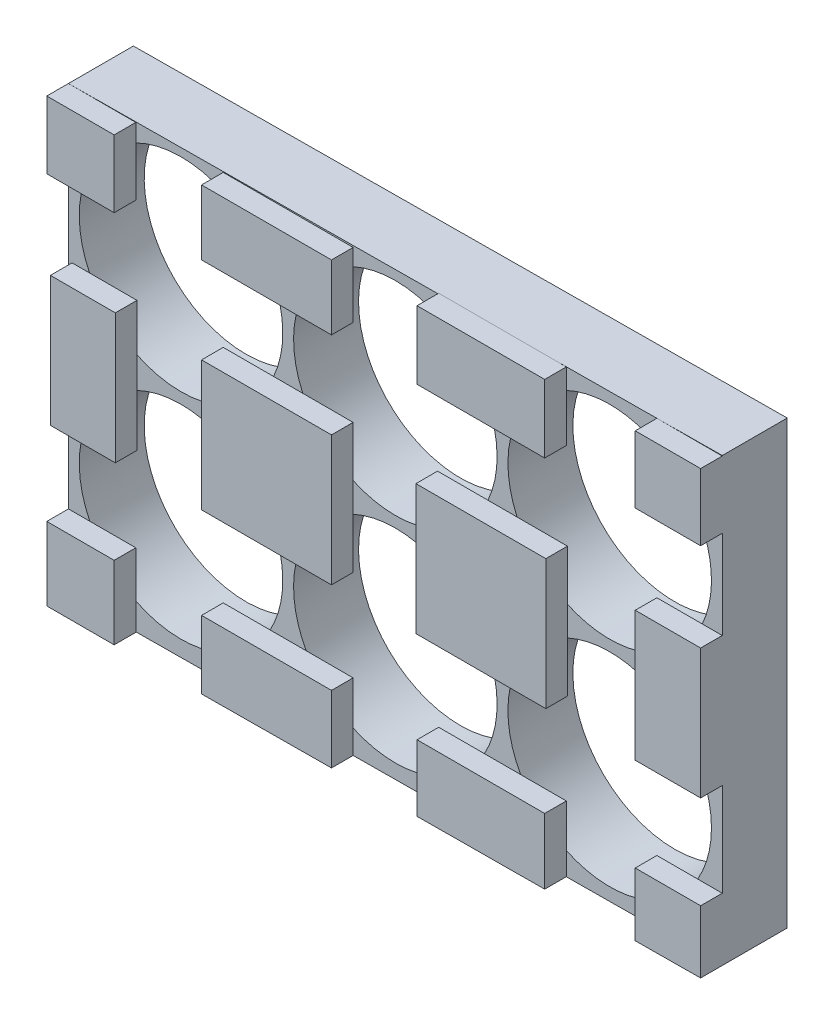
from build123d import *

# Parameters (mm, degrees)
MODEL_R         = 9.4
MODEL_R_2       = 2.5
EXTRUDE_1_DEPTH = 6
SKETCH_2_W      = 6.222861065
SKETCH_2_H      = 6.222861065
SKETCH_2_W_2    = 12
SKETCH_2_H_2    = 6
SKETCH_2_W_3    = 11.79
SKETCH_2_H_3    = 6.29
SKETCH_2_W_4    = 6.039723033
SKETCH_2_H_4    = 6.178960273
SKETCH_2_H_5    = 12
SKETCH_2_W_5    = 6
SKETCH_2_H_6    = 6.764977387
EXTRUDE_2_DEPTH = 2


with BuildPart() as part:
    # Model → 凸台-拉伸1 (new body)
    with BuildSketch(Plane.XY):
        Polygon((1072.862228674, 1168.347447046), (1072.862228674, 1127.547447046), (1012.463824187, 1127.108430595), (1012.463824187, 1167.908430595), align=None)
        with Locations((1022.862228674, 1157.847447046)):
            Circle(MODEL_R, mode=Mode.SUBTRACT)
        with Locations((1042.662228674, 1157.847447046)):
            Circle(MODEL_R, mode=Mode.SUBTRACT)
        with Locations((1062.462228674, 1157.847447046)):
            Circle(MODEL_R, mode=Mode.SUBTRACT)
        with Locations((1022.862228674, 1138.047447046)):
            Circle(MODEL_R, mode=Mode.SUBTRACT)
        with Locations((1042.662228674, 1138.047447046)):
            Circle(MODEL_R, mode=Mode.SUBTRACT)
        with Locations((1062.462228674, 1138.047447046)):
            Circle(MODEL_R, mode=Mode.SUBTRACT)
        with Locations((1032.762228674, 1147.947447046)):
            Circle(MODEL_R_2, mode=Mode.SUBTRACT)
        with Locations((1052.562228674, 1147.947447046)):
            Circle(MODEL_R_2, mode=Mode.SUBTRACT)
    extrude(amount=EXTRUDE_1_DEPTH)

    # 草图2 → 凸台-拉伸2 (add)
    with BuildSketch(Plane.XY.offset(6)):
        with Locations((1015.57525472, 1164.797000063)):
            Rectangle(SKETCH_2_W, SKETCH_2_H)
        Polygon((1072.862228674, 1133.328066092), (1072.862228674, 1127.547447046), (1066.822505641, 1127.503546254), (1066.822505641, 1133.328066092), align=None)
        with Locations((1032.763038583, 1164.944548481)):
            Rectangle(SKETCH_2_W_2, SKETCH_2_H_2)
        with Locations((1052.562228674, 1165.088462385)):
            Rectangle(SKETCH_2_W_3, SKETCH_2_H_3)
        with Locations((1069.842367158, 1165.214066118)):
            Rectangle(SKETCH_2_W_4, SKETCH_2_H_4)
        with Locations((1032.762228674, 1147.947447046)):
            Rectangle(SKETCH_2_W_2, SKETCH_2_H_5)
        with Locations((1052.562228674, 1147.947447046)):
            Rectangle(SKETCH_2_W_2, SKETCH_2_H_5)
        with Locations((1069.842367158, 1147.947447046)):
            Rectangle(SKETCH_2_W_4, SKETCH_2_H_5)
        with Locations((1015.796351171, 1147.726326037)):
            Rectangle(SKETCH_2_W_5, SKETCH_2_H_5)
        Polygon((1058.457228674, 1127.45), (1058.457228674, 1133.509189688), (1046.667228674, 1133.509189688), (1046.667228674, 1127.38), align=None)
        Polygon((1038.763038583, 1127.3), (1038.763038583, 1133.508103592), (1026.763038583, 1133.508103592), (1026.763038583, 1127.22), align=None)
        with Locations((1015.57525472, 1130.493598172)):
            Rectangle(SKETCH_2_W, SKETCH_2_H_6)
    extrude(amount=EXTRUDE_2_DEPTH)


solid = part.part
